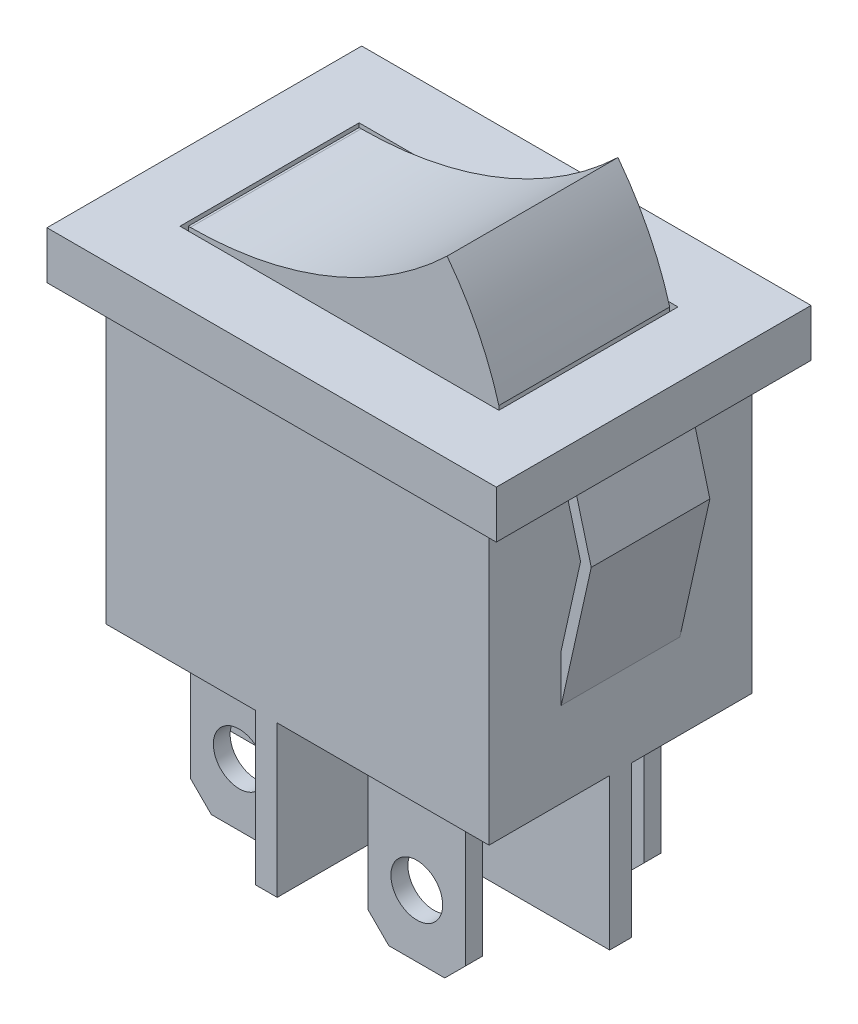
from build123d import *

# Parameters (mm, degrees)
SKETCH_1_W          = 18.5
SKETCH_1_H          = 16.4
EXTRUDE_1_DEPTH     = 6.35
SKETCH_2_W          = 21.7
SKETCH_2_H          = 15.2
EXTRUDE_2_DEPTH     = 2.3
EXTRUDE_3_DEPTH     = 2.865
EXTRUDE_4_DEPTH     = 7.3
SKETCH_5_W          = 4.7
SKETCH_5_H          = 0.81
SKETCH_5_H_2        = 0.82
EXTRUDE_5_DEPTH     = 8.25
CHAMFER_1_SIZE      = 1
SKETCH_6_R          = 1.25
CUT_EXTRUDE_1_DEPTH = 2.25
EXTRUDE_6_DEPTH     = 4.125
SKETCH_8_W          = 15.4
SKETCH_8_H          = 8.65
SKETCH_8_W_2        = 15
SKETCH_8_H_2        = 8.25
CUT_EXTRUDE_2_DEPTH = 1


with BuildPart() as part:
    # 草图1 → 凸台-拉伸1 (new body, symmetric)
    with BuildSketch(Plane.XY):
        Rectangle(SKETCH_1_W, SKETCH_1_H)
    extrude(amount=EXTRUDE_1_DEPTH, both=True)

    # 草图2 → 凸台-拉伸2 (add)
    with BuildSketch(Plane(origin=(0, 8.2, 0), x_dir=(1, 0, 0), z_dir=(0, 1, 0))):
        Rectangle(SKETCH_2_W, SKETCH_2_H)
    extrude(amount=-EXTRUDE_2_DEPTH)

    # 草图3 → 凸台-拉伸3 (add, symmetric)
    with BuildSketch(Plane.XY):
        Polygon((9.25, 5.9), (9.767443892, 5.9), (10.7, 2.4), (9.25, -4.1), (9.25, -1.80352853), (10.185361465, 2.389471142), align=None)
        Polygon((-10.185361465, 2.389471142), (-9.25, 5.9), (-9.767443892, 5.9), (-10.7, 2.4), (-9.25, -4.1), (-9.25, -1.80352853), align=None)
    extrude(amount=EXTRUDE_3_DEPTH, both=True)

    # 草图4 → 凸台-拉伸4 (add)
    with BuildSketch(Plane.XZ.offset(8.2)):
        Polygon((-9.25, 0.525), (-2.03, 0.525), (-2.03, 6.35), (-0.98, 6.35), (-0.98, 0.525), (9.25, 0.525), (9.25, -0.525), (-0.98, -0.525), (-0.98, -6.35), (-2.03, -6.35), (-2.03, -0.525), (-9.25, -0.525), align=None)
    extrude(amount=EXTRUDE_4_DEPTH)

    # 草图5 → 凸台-拉伸5 (add)
    with BuildSketch(Plane.XZ.offset(8.2)):
        with Locations((-5.64, 3.12)):
            Rectangle(SKETCH_5_W, SKETCH_5_H)
        with Locations((4.135, 4.315)):
            Rectangle(SKETCH_5_W, SKETCH_5_H_2)
        with Locations((4.135, -4.315)):
            Rectangle(SKETCH_5_W, SKETCH_5_H_2)
        with Locations((-5.64, -3.12)):
            Rectangle(SKETCH_5_W, SKETCH_5_H)
    extrude(amount=EXTRUDE_5_DEPTH)

    # 倒角1
    chamfer_1_edges = [part.edges().sort_by_distance(p)[0] for p in [
        (-3.29, -16.45, 3.12),
        (-7.99, -16.45, 3.12),
        (6.485, -16.45, 4.315),
        (1.785, -16.45, 4.315),
        (1.785, -16.45, -4.315),
        (6.485, -16.45, -4.315),
        (-7.99, -16.45, -3.12),
        (-3.29, -16.45, -3.12),
    ]]
    chamfer(chamfer_1_edges, length=CHAMFER_1_SIZE)

    # 草图6 → 切除-拉伸1 (cut)
    with BuildSketch(Plane.XY.offset(4.725)):
        with Locations((4.135, -13.45)):
            Circle(SKETCH_6_R)
        with Locations((-5.64, -13.45)):
            Circle(SKETCH_6_R)
    cut_extrude_1 = extrude(amount=-CUT_EXTRUDE_1_DEPTH, mode=Mode.SUBTRACT)

    # 镜向1: 切除-拉伸1 across plane
    add(cut_extrude_1.mirror(Plane.XY), mode=Mode.SUBTRACT)

    # 草图7 → 凸台-拉伸6 (add, symmetric)
    with BuildSketch(Plane.XY):
        with BuildLine():
            ThreePointArc((5, 13.2), (6.484981539, 10.817490769), (7.5, 8.2))
            Line((7.5, 8.2), (-7.5, 8.2))
            ThreePointArc((-7.5, 8.2), (-0.764940017, 9.487350042), (5, 13.2))
        make_face()
    extrude(amount=EXTRUDE_6_DEPTH, both=True)

    # 草图8 → 切除-拉伸2 (cut)
    with BuildSketch(Plane(origin=(0, 8.2, 0), x_dir=(1, 0, 0), z_dir=(0, 1, 0))):
        Rectangle(SKETCH_8_W, SKETCH_8_H)
        Rectangle(SKETCH_8_W_2, SKETCH_8_H_2, mode=Mode.SUBTRACT)
    extrude(amount=-CUT_EXTRUDE_2_DEPTH, mode=Mode.SUBTRACT)


solid = part.part
